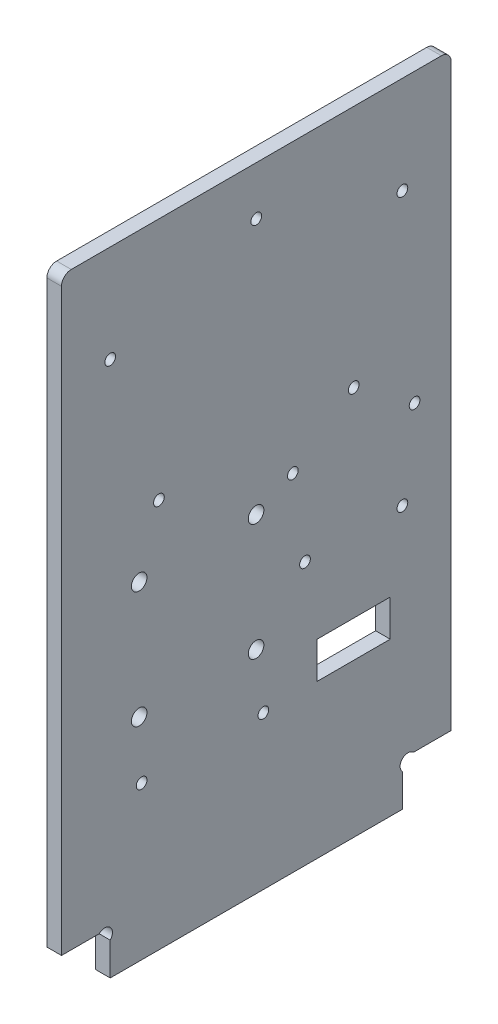
from build123d import *

# Parameters (mm, degrees)
EXTRUSION1_DEPTH        = 3
ESQUISSE2_R             = 1.1
ESQUISSE2_R_2           = 1.6
ENL_V_MAT_EXTRU_1_DEPTH = 4
ESQUISSE3_W             = 15
ESQUISSE3_H             = 7.5
ENL_V_MAT_EXTRU_2_DEPTH = 4
CONG_1_R                = 2
ESQUISSE5_R             = 1.1
ENL_V_MAT_EXTRU_6_DEPTH = 4


with BuildPart() as part:
    # Esquisse1 → Extrusion1 (new body)
    with BuildSketch(Plane(origin=(0, 0, 0), x_dir=(0, 0, -1), z_dir=(1, 0, 0))):
        with BuildLine():
            Line((10, 6.7372583), (10, 0))
            Line((10, 0), (70, 0))
            Line((70, 0), (70, 6.7372583))
            ThreePointArc((70, 6.7372583), (70, 9), (72.2627417, 9))
            Line((72.2627417, 9), (80, 9))
            Line((80, 9), (80, 130))
            Line((80, 130), (0, 130))
            Line((0, 130), (0, 9))
            Line((0, 9), (7.7372583, 9))
            ThreePointArc((7.7372583, 9), (10, 9), (10, 6.7372583))
        make_face()
    extrude(amount=EXTRUSION1_DEPTH)

    # Esquisse2 → Enlèv. mat.-Extru.1 (cut, through all)
    with BuildSketch(Plane(origin=(3, 0, 0), x_dir=(0, 0, -1), z_dir=(1, 0, 0))):
        with Locations((60, 80)):
            Circle(ESQUISSE2_R)
        with Locations((10, 110)):
            Circle(ESQUISSE2_R)
        with Locations(Location((20, 80, 0), (0, 0, 180))):  # turned: the seam where the file's is
            Circle(ESQUISSE2_R)
        with Locations((70, 110)):
            Circle(ESQUISSE2_R)
        with Locations((15.95, 67.45)):
            Circle(ESQUISSE2_R_2)
        with Locations((15.95, 43.45)):
            Circle(ESQUISSE2_R_2)
        with Locations((39.95, 43.45)):
            Circle(ESQUISSE2_R_2)
        with Locations((39.95, 67.45)):
            Circle(ESQUISSE2_R_2)
        with Locations((40, 120)):
            Circle(ESQUISSE2_R)
        with Locations((70, 54)):
            Circle(ESQUISSE2_R)
        with Locations((50, 54)):
            Circle(ESQUISSE2_R)
    extrude(amount=-ENL_V_MAT_EXTRU_1_DEPTH, mode=Mode.SUBTRACT)

    # Esquisse3 → Enlèv. mat.-Extru.2 (cut, through all)
    with BuildSketch(Plane.ZY):
        with Locations((-60, 35.25)):
            Rectangle(ESQUISSE3_W, ESQUISSE3_H)
    extrude(amount=-ENL_V_MAT_EXTRU_2_DEPTH, mode=Mode.SUBTRACT)

    # Congé1
    cong_1_edges = [part.edges().sort_by_distance(p)[0] for p in [
        (1.5, 130, 0),
        (1.5, 130, -80),
    ]]
    fillet(cong_1_edges, radius=CONG_1_R)

    # Esquisse5 → Enlèv. mat.-Extru.6 (cut, through all)
    with BuildSketch(Plane(origin=(3, 0, 0), x_dir=(0, 0, -1), z_dir=(1, 0, 0))):
        with Locations((16.45, 31.45)):
            Circle(ESQUISSE5_R)
        with Locations((41.45, 31.45)):
            Circle(ESQUISSE5_R)
        with Locations((47.5, 71)):
            Circle(ESQUISSE5_R)
        with Locations((72.5, 71)):
            Circle(ESQUISSE5_R)
    extrude(amount=-ENL_V_MAT_EXTRU_6_DEPTH, mode=Mode.SUBTRACT)


solid = part.part
